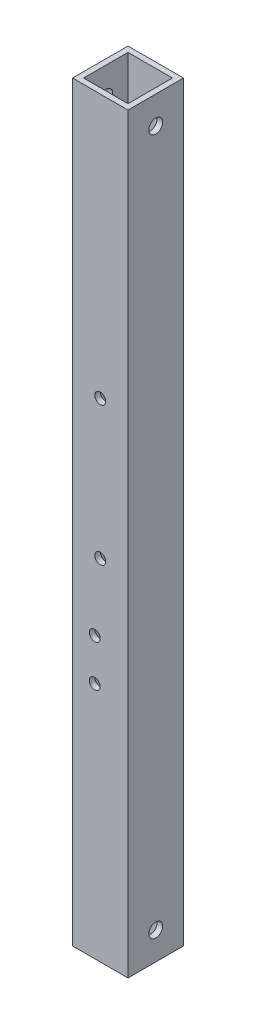
from build123d import *

# Parameters (mm, degrees)
SKETCH1_W           = 25.4
SKETCH1_H           = 25.4
SKETCH1_W_2         = 20.32
SKETCH1_H_2         = 20.32
EXTRUDE_THIN1_DEPTH = 344.17
SKETCH2_R           = 2.4892
CUT_EXTRUDE1_DEPTH  = 26.4
SKETCH4_R           = 3.175
CUT_EXTRUDE3_DEPTH  = 26.4


with BuildPart() as part:
    # Sketch1 → Extrude-Thin1 (new body)
    with BuildSketch(Plane(origin=(0, 0, 0), x_dir=(1, 0, 0), z_dir=(0, 1, 0))):
        with Locations((12.7, 12.7)):
            Rectangle(SKETCH1_W, SKETCH1_H)
        with Locations((12.7, 12.7)):
            Rectangle(SKETCH1_W_2, SKETCH1_H_2, mode=Mode.SUBTRACT)
    extrude(amount=EXTRUDE_THIN1_DEPTH)

    # Sketch2 → Cut-Extrude1 (cut, through all)
    with BuildSketch(Plane(origin=(0, 0, -25.4), x_dir=(-1, 0, 0), z_dir=(0, 0, -1))):
        with Locations((-10.16, 109.1191)):
            Circle(SKETCH2_R)
        with Locations((-10.16, 128.1691)):
            Circle(SKETCH2_R)
        with Locations((-12.7, 160.02)):
            Circle(SKETCH2_R)
        with Locations((-12.7, 223.52)):
            Circle(SKETCH2_R)
    extrude(amount=-CUT_EXTRUDE1_DEPTH, mode=Mode.SUBTRACT)

    # Sketch4 → Cut-Extrude3 (cut, through all)
    with BuildSketch(Plane.ZY):
        with Locations((-12.7, 12.7)):
            Circle(SKETCH4_R)
        with Locations((-12.7, 331.47)):
            Circle(SKETCH4_R)
    extrude(amount=-CUT_EXTRUDE3_DEPTH, mode=Mode.SUBTRACT)


solid = part.part
